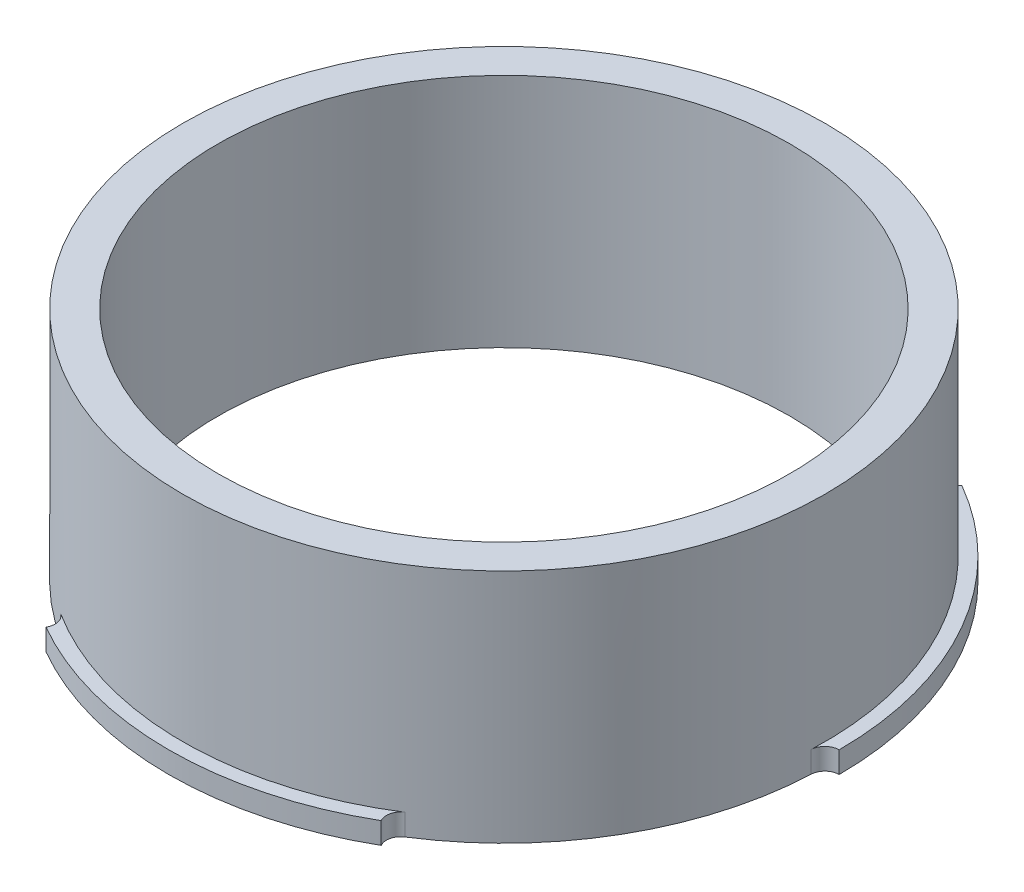
from build123d import *

# Parameters (mm, degrees)
SKETCH1_R           = 22.475
SKETCH1_R_2         = 20
BOSS_EXTRUDE1_DEPTH = 15
SKETCH2_R           = 23.455
SKETCH2_R_2         = 20
BOSS_EXTRUDE2_DEPTH = 1.5
CUT_EXTRUDE3_DEPTH  = 10
CIRPATTERN1_COUNT   = 3
FILLET1_R           = 1


with BuildPart() as part:
    # Sketch1 → Boss-Extrude1 (new body)
    with BuildSketch(Plane(origin=(0, 0, 0), x_dir=(1, 0, 0), z_dir=(0, 1, 0))):
        with Locations(Location((0, 0, 0), (0, 0, 270))):
            Circle(SKETCH1_R)
        with Locations(Location((0, 0, 0), (0, 0, 270))):
            Circle(SKETCH1_R_2, mode=Mode.SUBTRACT)
    extrude(amount=BOSS_EXTRUDE1_DEPTH)

    # Sketch2 → Boss-Extrude2 (add)
    with BuildSketch(Plane.XZ):
        with Locations(Location((0, 0, 0), (0, 0, 270))):
            Circle(SKETCH2_R)
        with Locations(Location((0, 0, 0), (0, 0, 270))):
            Circle(SKETCH2_R_2, mode=Mode.SUBTRACT)
    extrude(amount=BOSS_EXTRUDE2_DEPTH)

    # Sketch4 → Cut-Extrude3 (cut)
    with BuildSketch(Plane(origin=(0, 0, 0), x_dir=(1, 0, 0), z_dir=(0, 1, 0))):
        with BuildLine():
            Line((-11.2375, 19.463921), (-11.7275, 20.312626))
            ThreePointArc((-11.7275, 20.312626), (0, 23.455), (11.7275, 20.312626))
            Line((11.7275, 20.312626), (11.2375, 19.463921))
            ThreePointArc((11.2375, 19.463921), (0, 22.475), (-11.2375, 19.463921))
        make_face()
    cut_extrude3 = extrude(amount=-CUT_EXTRUDE3_DEPTH, mode=Mode.SUBTRACT)

    # CirPattern1: Cut-Extrude3 ×3 about axis
    cirpattern1_axis = Axis((0, 0, 0), (0, 1, 0))
    for i in range(1, CIRPATTERN1_COUNT):
        add(cut_extrude3.rotate(cirpattern1_axis, i * 360 / CIRPATTERN1_COUNT), mode=Mode.SUBTRACT)

    # Fillet1
    fillet1_edges = [part.edges().sort_by_distance(p)[0] for p in [
        (11.2375, -0.75, -19.463921),
        (-11.2375, -0.75, -19.463921),
        (-22.475, -0.75, 0),
        (-11.2375, -0.75, 19.463921),
        (11.2375, -0.75, 19.463921),
        (22.475, -0.75, 0),
    ]]
    fillet(fillet1_edges, radius=FILLET1_R)


solid = part.part
